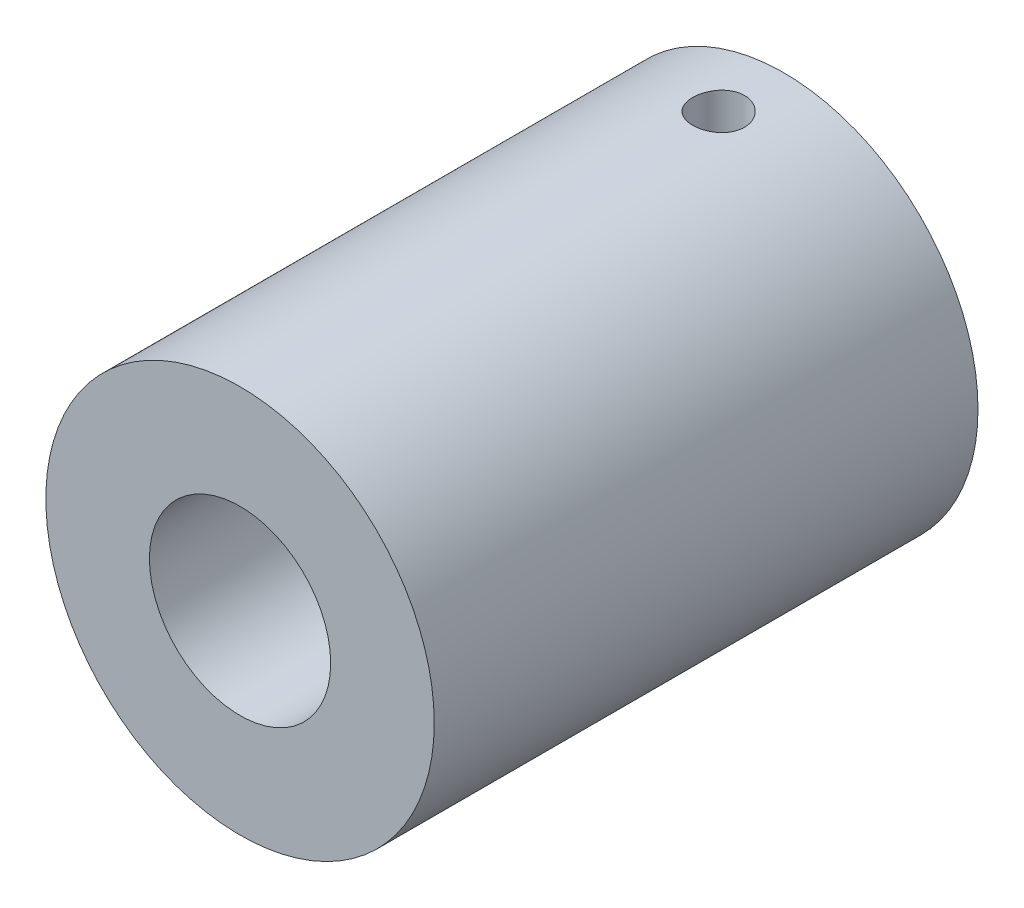
from build123d import *

# Parameters (mm, degrees)
SKETCH_1_R               = 15
EXTRUDE_1_DEPTH          = 42
SKETCH_2_R               = 7
CUT_EXTRUDE_1_DEPTH      = 20
SKETCH_3_R               = 5
CUT_EXTRUDE_2_DEPTH      = 20
SKETCH_5_R               = 2
CUT_EXTRUDE_3_DEPTH      = 20
CUT_EXTRUDE_3_DEPTH_BACK = 10


with BuildPart() as part:
    # 草图1 → 凸台-拉伸1 (new body)
    with BuildSketch(Plane.XY):
        with Locations((0, -2.373543689)):
            Circle(SKETCH_1_R)
    extrude(amount=EXTRUDE_1_DEPTH)

    # 草图2 → 切除-拉伸1 (cut)
    with BuildSketch(Plane.XY.offset(42)):
        with Locations((0, -2.373543689)):
            Circle(SKETCH_2_R)
    extrude(amount=-CUT_EXTRUDE_1_DEPTH, mode=Mode.SUBTRACT)

    # 草图3 → 切除-拉伸2 (cut)
    with BuildSketch(Plane(origin=(0, 0, 0), x_dir=(-1, 0, 0), z_dir=(0, 0, -1))):
        with Locations((0, -2.373543689)):
            Circle(SKETCH_3_R)
    extrude(amount=-CUT_EXTRUDE_2_DEPTH, mode=Mode.SUBTRACT)

    # 草图5 → 切除-拉伸3 (cut, two sides)
    with BuildSketch(Plane(origin=(0, 10, 0), x_dir=(1, 0, 0), z_dir=(0, 1, 0))) as cut_extrude_3_sk:
        with Locations((0, -5.037121645)):
            Circle(SKETCH_5_R)
    extrude(amount=CUT_EXTRUDE_3_DEPTH, mode=Mode.SUBTRACT)
    extrude(cut_extrude_3_sk.sketch, amount=-CUT_EXTRUDE_3_DEPTH_BACK, mode=Mode.SUBTRACT)


solid = part.part
